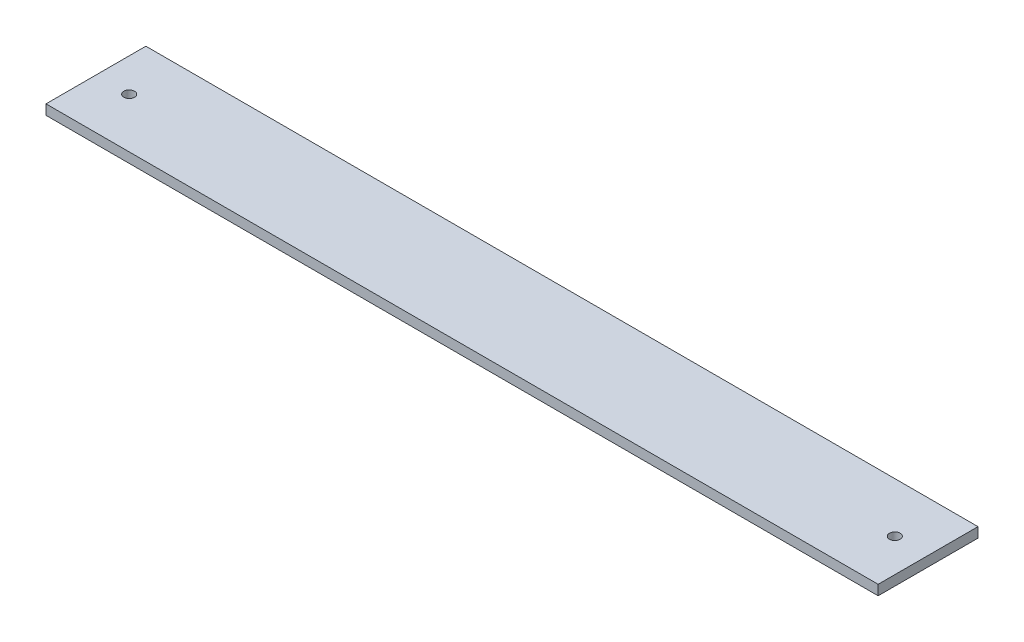
from build123d import *

# Parameters (mm, degrees)
SKETCH1_W           = 250
SKETCH1_H           = 30
SKETCH1_R           = 1.6
BOSS_EXTRUDE1_DEPTH = 3


with BuildPart() as part:
    # Sketch1 → Boss-Extrude1 (new body)
    with BuildSketch(Plane(origin=(0, 0, 0), x_dir=(1, 0, 0), z_dir=(0, 1, 0))):
        Rectangle(SKETCH1_W, SKETCH1_H)
        with Locations((-115, 0)):
            Circle(SKETCH1_R, mode=Mode.SUBTRACT)
        with Locations((115, 0)):
            Circle(SKETCH1_R, mode=Mode.SUBTRACT)
    extrude(amount=BOSS_EXTRUDE1_DEPTH)


solid = part.part
